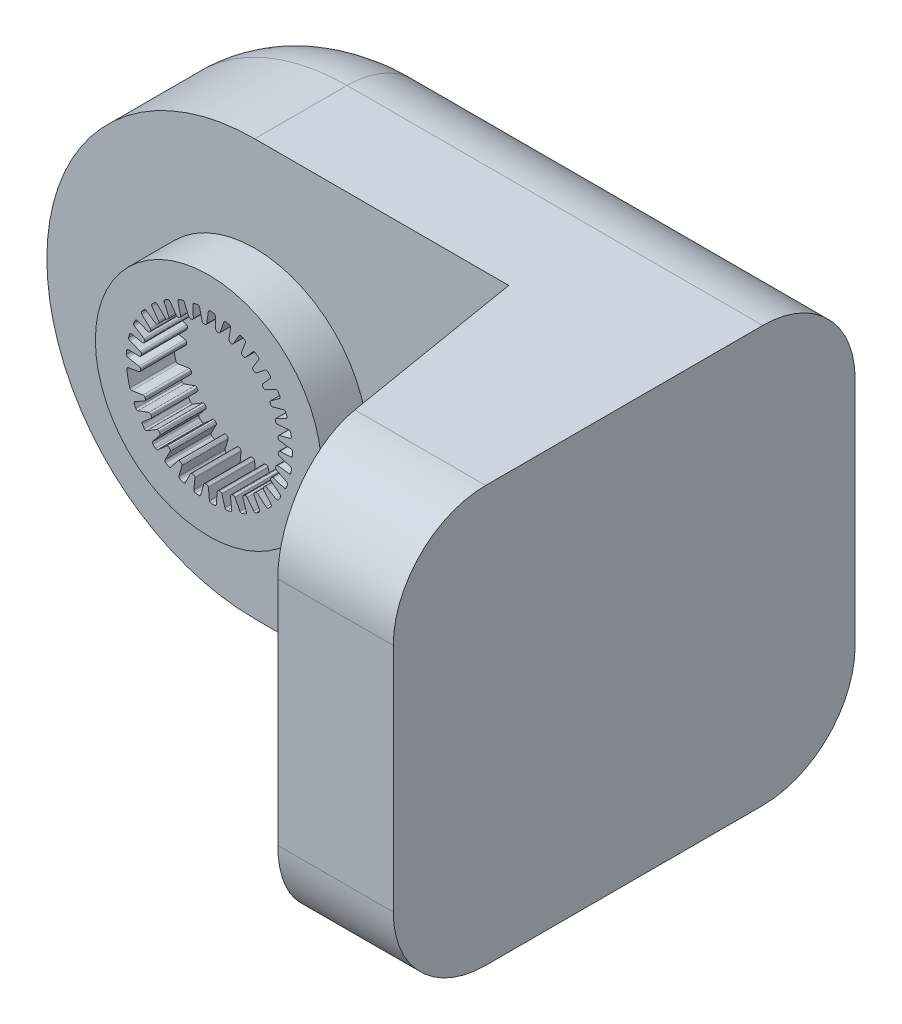
from build123d import *

# Parameters (mm, degrees)
SKETCH1_R           = 24.5
BOSS_EXTRUDE1_DEPTH = 10
BOSS_EXTRUDE3_DEPTH = 40
SKETCH7_W           = 35
SKETCH7_H           = 90
BOSS_EXTRUDE4_DEPTH = 60
CUT_EXTRUDE1_DEPTH  = 91
FILLET1_R           = 20
FILLET2_R           = 20
SCALE1_SCALE        = 0.3


with BuildPart() as part:
    # Sketch1 → Boss-Extrude1 (new body)
    with BuildSketch(Plane.XY):
        with Locations((-0.371975008, 0)):
            Circle(SKETCH1_R)
        with BuildLine():
            Line((-16.969142825, -5.497864624), (-14.564977721, -5.124585631))
            ThreePointArc((-14.564977721, -5.124585631), (-14.29707046, -5.177296982), (-14.125400218, -5.389622476))
            Line((-14.125400218, -5.389622476), (-14.049847687, -5.60904296))
            ThreePointArc((-14.049847687, -5.60904296), (-14.054138659, -5.881349365), (-14.231761388, -6.087793926))
            Line((-14.231761388, -6.087793926), (-16.278130424, -7.240339372))
            ThreePointArc((-16.278130424, -7.240339372), (-16.462911631, -7.467282264), (-16.443705401, -7.759306734))
            ThreePointArc((-16.443705401, -7.759306734), (-16.284490349, -8.088614134), (-16.11861668, -8.414618309))
            ThreePointArc((-16.11861668, -8.414618309), (-15.909353928, -8.602256969), (-15.62830969, -8.605904202))
            Line((-15.62830969, -8.605904202), (-13.33954086, -7.780747067))
            ThreePointArc((-13.33954086, -7.780747067), (-13.06649801, -7.781370848), (-12.857468219, -7.957039097))
            Line((-12.857468219, -7.957039097), (-12.741436398, -8.158012106))
            ThreePointArc((-12.741436398, -8.158012106), (-12.693690022, -8.426134232), (-12.828657842, -8.662677839))
            Line((-12.828657842, -8.662677839), (-14.617513276, -10.1845134))
            ThreePointArc((-14.617513276, -10.1845134), (-14.755596786, -10.442544627), (-14.681022533, -10.725539064))
            ThreePointArc((-14.681022533, -10.725539064), (-14.461897897, -11.018416496), (-14.236867265, -11.306780868))
            ThreePointArc((-14.236867265, -11.306780868), (-13.995646114, -11.451042861), (-13.719069526, -11.400997316))
            Line((-13.719069526, -11.400997316), (-11.62979923, -10.15428296))
            ThreePointArc((-11.62979923, -10.15428296), (-11.361653923, -10.102796248), (-11.122945516, -10.235352213))
            Line((-11.122945516, -10.235352213), (-10.970698069, -10.410492867))
            ThreePointArc((-10.970698069, -10.410492867), (-10.872668815, -10.664578395), (-10.960022248, -10.922529105))
            Line((-10.960022248, -10.922529105), (-12.425631454, -12.757733968))
            ThreePointArc((-12.425631454, -12.757733968), (-12.511943302, -13.037372011), (-12.384741304, -13.300937604))
            ThreePointArc((-12.384741304, -13.300937604), (-12.113758956, -13.546623101), (-11.837840254, -13.786751538))
            ThreePointArc((-11.837840254, -13.786751538), (-11.57352453, -13.882335867), (-11.311578572, -13.780436499))
            Line((-11.311578572, -13.780436499), (-9.49857837, -12.157976231))
            ThreePointArc((-9.49857837, -12.157976231), (-9.245183775, -12.056270938), (-8.985568244, -12.140843765))
            Line((-8.985568244, -12.140843765), (-8.802699599, -12.28371641))
            ThreePointArc((-8.802699599, -12.28371641), (-8.657989614, -12.514428808), (-8.694518802, -12.784308057))
            Line((-8.694518802, -12.784308057), (-9.783027044, -14.865446458))
            ThreePointArc((-9.783027044, -14.865446458), (-9.814395646, -15.15641584), (-9.63924002, -15.390867705))
            ThreePointArc((-9.63924002, -15.390867705), (-9.326357378, -15.580333398), (-9.009689414, -15.763402229))
            ThreePointArc((-9.009689414, -15.763402229), (-8.731991565, -15.806796587), (-8.494301608, -15.656787752))
            Line((-8.494301608, -15.656787752), (-7.02419134, -13.718199902))
            ThreePointArc((-7.02419134, -13.718199902), (-6.794858602, -13.570013254), (-6.523875683, -13.603495261))
            Line((-6.523875683, -13.603495261), (-6.317105464, -13.70884995))
            ThreePointArc((-6.317105464, -13.70884995), (-6.131032208, -13.907711545), (-6.115394864, -14.179602449))
            Line((-6.115394864, -14.179602449), (-6.786804216, -16.430201641))
            ThreePointArc((-6.786804216, -16.430201641), (-6.762076913, -16.721810507), (-6.545403865, -16.918533562))
            ThreePointArc((-6.545403865, -16.918533562), (-6.202118, -17.044817414), (-5.856336939, -17.164099659))
            ThreePointArc((-5.856336939, -17.164099659), (-5.575461147, -17.153709492), (-5.370761259, -16.96110336))
            Line((-5.370761259, -16.96110336), (-4.297561057, -14.777622566))
            ThreePointArc((-4.297561057, -14.777622566), (-4.100717154, -14.588399775), (-3.828324286, -14.569560645))
            Line((-3.828324286, -14.569560645), (-3.605250396, -14.633526053))
            ThreePointArc((-3.605250396, -14.633526053), (-3.384651249, -14.79322955), (-3.317421976, -15.057141307))
            Line((-3.317421976, -15.057141307), (-3.547061077, -17.394501596))
            ThreePointArc((-3.547061077, -17.394501596), (-3.467146489, -17.676034594), (-3.216917807, -17.827800126))
            ThreePointArc((-3.216917807, -17.827800126), (-2.855842975, -17.886261756), (-2.49365476, -17.937374314))
            ThreePointArc((-2.49365476, -17.937374314), (-2.219921985, -17.873581416), (-2.055733994, -17.645455421))
            Line((-2.055733994, -17.645455421), (-1.418879279, -15.297315067))
            ThreePointArc((-1.418879279, -15.297315067), (-1.261757363, -15.074009244), (-0.997963795, -15.003541232))
            Line((-0.997963795, -15.003541232), (-0.766783225, -15.023766911))
            ThreePointArc((-0.766783225, -15.023766911), (-0.519764242, -15.138443903), (-0.403413423, -15.384678908))
            Line((-0.403413423, -15.384678908), (-0.182844038, -17.722912511))
            ThreePointArc((-0.182844038, -17.722912511), (-0.050678678, -17.984024533), (0.223910828, -18.085255821))
            ThreePointArc((0.223910828, -18.085255821), (0.589506703, -18.073747021), (0.954793236, -18.054811727))
            ThreePointArc((0.954793236, -18.054811727), (1.21132451, -17.939960209), (1.328967414, -17.684696986))
            Line((1.328967414, -17.684696986), (1.506075012, -15.258180974))
            ThreePointArc((1.506075012, -15.258180974), (1.617701396, -15.008997633), (1.863202402, -14.889490132))
            Line((1.863202402, -14.889490132), (2.093994776, -14.865232876))
            ThreePointArc((2.093994776, -14.865232876), (2.358356726, -14.930669484), (2.519553706, -15.150179676))
            Line((2.519553706, -15.150179676), (3.182226615, -17.403366719))
            ThreePointArc((3.182226615, -17.403366719), (3.361786248, -17.634463038), (3.650646611, -17.681440275))
            ThreePointArc((3.650646611, -17.681440275), (4.007329478, -17.600383942), (4.362291644, -17.512096587))
            ThreePointArc((4.362291644, -17.512096587), (4.592195013, -17.35040674), (4.658969966, -17.077386096))
            Line((4.658969966, -17.077386096), (4.369822517, -14.661658296))
            ThreePointArc((4.369822517, -14.661658296), (4.431851587, -14.395753836), (4.650038942, -14.231598224))
            Line((4.650038942, -14.231598224), (4.871962507, -14.163749381))
            ThreePointArc((4.871962507, -14.163749381), (5.143953277, -14.177541097), (5.344073133, -14.362260434))
            Line((5.344073133, -14.362260434), (6.424499231, -16.447606133))
            ThreePointArc((6.424499231, -16.447606133), (6.644855104, -16.640194968), (6.937371968, -16.631191945))
            ThreePointArc((6.937371968, -16.631191945), (7.272035289, -16.483566546), (7.603629778, -16.329171304))
            ThreePointArc((7.603629778, -16.329171304), (7.798457298, -16.126584524), (7.811910612, -15.845838777))
            Line((7.811910612, -15.845838777), (7.067133021, -13.529666635))
            ThreePointArc((7.067133021, -13.529666635), (7.077285479, -13.256811885), (7.260141751, -13.054040163))
            Line((7.260141751, -13.054040163), (7.465041785, -12.945092882))
            ThreePointArc((7.465041785, -12.945092882), (7.734666902, -12.906732919), (7.966356105, -13.049873773))
            Line((7.966356105, -13.049873773), (9.42483445, -14.89075078))
            ThreePointArc((9.42483445, -14.89075078), (9.677889447, -15.037755333), (9.963314095, -14.973102872))
            ThreePointArc((9.963314095, -14.973102872), (10.263660453, -14.764332996), (10.559702617, -14.549503217))
            ThreePointArc((10.559702617, -14.549503217), (10.712295226, -14.313463684), (10.671932552, -14.035309014))
            Line((10.671932552, -14.035309014), (9.498892143, -11.903801741))
            ThreePointArc((9.498892143, -11.903801741), (9.456794931, -11.634022921), (9.597600949, -11.400086065))
            Line((9.597600949, -11.400086065), (9.777948272, -11.254043683))
            ThreePointArc((9.777948272, -11.254043683), (10.03530019, -11.164941603), (10.290045172, -11.261244173))
            Line((10.290045172, -11.261244173), (12.072983054, -12.790008296))
            ThreePointArc((12.072983054, -12.790008296), (12.349438509, -12.886026792), (12.617282831, -12.768100588))
            ThreePointArc((12.617282831, -12.768100588), (12.872275811, -12.505857615), (13.121887392, -12.238487357))
            ThreePointArc((13.121887392, -12.238487357), (13.226637979, -11.977668492), (13.133942467, -11.712325868))
            Line((13.133942467, -11.712325868), (11.575743353, -9.84380705))
            ThreePointArc((11.575743353, -9.84380705), (11.48294336, -9.587017353), (11.576525119, -9.330511522))
            Line((11.576525119, -9.330511522), (11.725692753, -9.152740458))
            ThreePointArc((11.725692753, -9.152740458), (11.961314913, -9.016170373), (12.229754908, -9.062095959))
            Line((12.229754908, -9.062095959), (14.271637147, -10.222571794))
            ThreePointArc((14.271637147, -10.222571794), (14.561334529, -10.264075972), (14.801756416, -10.097209299))
            ThreePointArc((14.801756416, -10.097209299), (15.002026138, -9.791129513), (15.196035002, -9.481043465))
            ThreePointArc((15.196035002, -9.481043465), (15.24909444, -9.205029223), (15.107472246, -8.962248828))
            Line((15.107472246, -8.962248828), (13.22137144, -7.42537837))
            ThreePointArc((13.22137144, -7.42537837), (13.08127866, -7.191013697), (13.124197438, -6.921364359))
            Line((13.124197438, -6.921364359), (13.236704125, -6.718396924))
            ThreePointArc((13.236704125, -6.718396924), (13.441938441, -6.539377188), (13.714209453, -6.533238226))
            Line((13.714209453, -6.533238226), (15.940005792, -7.282783352))
            ThreePointArc((15.940005792, -7.282783352), (16.232299988, -7.268248115), (16.436464985, -7.058572594))
            ThreePointArc((16.436464985, -7.058572594), (16.574652412, -6.719903092), (16.705929579, -6.378495562))
            ThreePointArc((16.705929579, -6.378495562), (16.705348165, -6.09742826), (16.520003287, -5.886131214))
            Line((16.520003287, -5.886131214), (14.375306757, -4.737382395))
            ThreePointArc((14.375306757, -4.737382395), (14.193068988, -4.534054623), (14.183747708, -4.261170214))
            Line((14.183747708, -4.261170214), (14.255459317, -4.040464575))
            ThreePointArc((14.255459317, -4.040464575), (14.422764326, -3.825573383), (14.688861583, -3.767595452))
            Line((14.688861583, -3.767595452), (17.016783726, -4.07866736))
            ThreePointArc((17.016783726, -4.07866736), (17.300934201, -4.008626814), (17.461340136, -3.763847105))
            ThreePointArc((17.461340136, -3.763847105), (17.532367484, -3.405032512), (17.596089091, -3.044848735))
            ThreePointArc((17.596089091, -3.044848735), (17.54188819, -2.76905637), (17.319631242, -2.597006915))
            Line((17.319631242, -2.597006915), (14.99514722, -1.878591239))
            ThreePointArc((14.99514722, -1.878591239), (14.777460905, -1.713771776), (14.716242083, -1.447679606))
            Line((14.716242083, -1.447679606), (14.744523527, -1.217345731))
            ThreePointArc((14.744523527, -1.217345731), (14.867751498, -0.974479394), (15.117897089, -0.866792932))
            Line((15.117897089, -0.866792932), (17.462404064, -0.727961087))
            ThreePointArc((17.462404064, -0.727961087), (17.727969528, -0.604988917), (17.838722184, -0.334099605))
            ThreePointArc((17.838722184, -0.334099605), (17.839979507, 0.031675211), (17.833804064, 0.397400053))
            ThreePointArc((17.833804064, 0.397400053), (17.727975323, 0.657783316), (17.476973277, 0.784263113))
            Line((17.476973277, 0.784263113), (15.0581164, 1.045947009))
            ThreePointArc((15.0581164, 1.045947009), (14.812980559, 1.166201766), (14.70211372, 1.415723972))
            Line((14.70211372, 1.415723972), (14.685925779, 1.647222319))
            ThreePointArc((14.685925779, 1.647222319), (14.760548624, 1.909139522), (14.985550789, 2.06257751))
            Line((14.985550789, 2.06257751), (17.260492203, 2.646211643))
            ThreePointArc((17.260492203, 2.646211643), (17.497714285, 2.817596748), (17.554743986, 3.104641663))
            ThreePointArc((17.554743986, 3.104641663), (17.486185083, 3.463936074), (17.410339511, 3.821763191))
            ThreePointArc((17.410339511, 3.821763191), (17.256771672, 4.057169404), (16.986247758, 4.133431962))
            Line((16.986247758, 4.133431962), (14.561900453, 3.928768337))
            ThreePointArc((14.561900453, 3.928768337), (14.298322759, 4.000039553), (14.141881775, 4.223822943))
            Line((14.141881775, 4.223822943), (14.081819284, 4.447979208))
            ThreePointArc((14.081819284, 4.447979208), (14.105094939, 4.719322965), (14.296685833, 4.912874302))
            Line((14.296685833, 4.912874302), (16.418467522, 5.919864718))
            ThreePointArc((16.418467522, 5.919864718), (16.618629347, 6.133365102), (16.6198405, 6.426017974))
            ThreePointArc((16.6198405, 6.426017974), (16.483984611, 6.765629479), (16.341255904, 7.102410286))
            ThreePointArc((16.341255904, 7.102410286), (16.145591916, 7.304189299), (15.865486706, 7.327432303))
            Line((15.865486706, 7.327432303), (13.52473315, 6.663941652))
            ThreePointArc((13.52473315, 6.663941652), (13.252398931, 6.68361042), (13.056132325, 6.873431931))
            Line((13.056132325, 6.873431931), (12.95440232, 7.082009351))
            ThreePointArc((12.95440232, 7.082009351), (12.925475505, 7.352808963), (13.076614998, 7.579361483))
            Line((13.076614998, 7.579361483), (14.967270753, 8.972705682))
            ThreePointArc((14.967270753, 8.972705682), (15.123017247, 9.220476139), (15.068365347, 9.507983253))
            ThreePointArc((15.068365347, 9.507983253), (14.870204584, 9.815432612), (14.665837397, 10.118791886))
            ThreePointArc((14.665837397, 10.118791886), (14.435267057, 10.279529201), (14.155873194, 10.248898572))
            Line((14.155873194, 10.248898572), (11.984725859, 9.150961278))
            ThreePointArc((11.984725859, 9.150961278), (11.713642209, 9.118304857), (11.484761921, 9.267189378))
            Line((11.484761921, 9.267189378), (11.345102535, 9.452523643))
            ThreePointArc((11.345102535, 9.452523643), (11.265036185, 9.712828408), (11.370170562, 9.964057294))
            Line((11.370170562, 9.964057294), (12.960227038, 11.692555961))
            ThreePointArc((12.960227038, 11.692555961), (13.065835198, 11.965492009), (12.957328464, 12.237288733))
            ThreePointArc((12.957328464, 12.237288733), (12.704144369, 12.501278525), (12.445648304, 12.760069138))
            ThreePointArc((12.445648304, 12.760069138), (12.188644066, 12.87385836), (11.920228055, 12.79047964))
            Line((11.920228055, 12.79047964), (9.998467123, 11.298440105))
            ThreePointArc((9.998467123, 11.298440105), (9.738595182, 11.214658475), (9.485511563, 11.317135151))
            Line((9.485511563, 11.317135151), (9.313054669, 11.472416036))
            ThreePointArc((9.313054669, 11.472416036), (9.184790873, 11.712660889), (9.240056903, 11.979334578))
            Line((9.240056903, 11.979334578), (10.47108647, 13.979472934))
            ThreePointArc((10.47108647, 13.979472934), (10.522675657, 14.267545366), (10.364301238, 14.513644357))
            ThreePointArc((10.364301238, 14.513644357), (10.065397221, 14.724474111), (9.76227088, 14.929186636))
            ThreePointArc((9.76227088, 14.929186636), (9.488276526, 14.99184651), (9.240701483, 14.858783502))
            Line((9.240701483, 14.858783502), (7.638943277, 13.027467663))
            ThreePointArc((7.638943277, 13.027467663), (7.399832204, 12.895639434), (7.131844973, 12.947942693))
            Line((7.131844973, 12.947942693), (6.932927607, 13.067464305))
            ThreePointArc((6.932927607, 13.067464305), (6.7611795, 13.278821297), (6.764546399, 13.551140695))
            Line((6.764546399, 13.551140695), (7.591314094, 15.749422391))
            ThreePointArc((7.591314094, 15.749422391), (7.586988632, 16.042045802), (7.384566095, 16.253403998))
            ThreePointArc((7.384566095, 16.253403998), (7.050925573, 16.40332664), (6.714307526, 16.546438787))
            ThreePointArc((6.714307526, 16.546438787), (6.433391152, 16.555666835), (6.215754379, 16.377809024))
            Line((6.215754379, 16.377809024), (4.992856518, 14.274509741))
            ThreePointArc((4.992856518, 14.274509741), (4.783292601, 14.099479023), (4.510249118, 14.09968695))
            Line((4.510249118, 14.09968695), (4.292180626, 14.17905739))
            ThreePointArc((4.292180626, 14.17905739), (4.0832592, 14.353760076), (4.034603248, 14.621718634))
            Line((4.034603248, 14.621718634), (4.426728971, 16.937366417))
            ThreePointArc((4.426728971, 16.937366417), (4.3666478, 17.223788175), (4.127615291, 17.392639084))
            ThreePointArc((4.127615291, 17.392639084), (3.771498096, 17.476145612), (3.413757585, 17.552398635))
            ThreePointArc((3.413757585, 17.552398635), (3.136241642, 17.507855766), (2.956540339, 17.29173865))
            Line((2.956540339, 17.29173865), (2.15743898, 14.993742987))
            ThreePointArc((2.15743898, 14.993742987), (1.985122778, 14.781941396), (1.717056198, 14.73004635))
            Line((1.717056198, 14.73004635), (1.487849644, 14.766349102))
            ThreePointArc((1.487849644, 14.766349102), (1.249431849, 14.897977919), (1.150540941, 15.151729331))
            Line((1.150540941, 15.151729331), (1.093615783, 17.499653257))
            ThreePointArc((1.093615783, 17.499653257), (0.979986625, 17.769348613), (0.713127543, 17.889487702))
            ThreePointArc((0.713127543, 17.889487702), (0.347619428, 17.903509616), (-0.018098145, 17.910101548))
            ThreePointArc((-0.018098145, 17.910101548), (-0.282016159, 17.81342452), (-0.417178752, 17.566989459))
            Line((-0.417178752, 17.566989459), (-0.763120125, 15.15873872))
            ThreePointArc((-0.763120125, 15.15873872), (-0.891856745, 14.91794904), (-1.145096145, 14.815857937))
            Line((-1.145096145, 14.815857937), (-1.37701842, 14.807759033))
            ThreePointArc((-1.37701842, 14.807759033), (-1.636171771, 14.891477199), (-1.781663826, 15.121697207))
            Line((-1.781663826, 15.121697207), (-2.285548115, 17.415621326))
            ThreePointArc((-2.285548115, 17.415621326), (-2.448549885, 17.658680152), (-2.733429633, 17.725692835))
            ThreePointArc((-2.733429633, 17.725692835), (-3.094897842, 17.669714891), (-3.455153952, 17.606403508))
            ThreePointArc((-3.455153952, 17.606403508), (-3.695776202, 17.461144777), (-3.781433452, 17.193447184))
            Line((-3.781433452, 17.193447184), (-3.661503004, 14.763434069))
            ThreePointArc((-3.661503004, 14.763434069), (-3.741929532, 14.502504268), (-3.97103631, 14.353968511))
            Line((-3.97103631, 14.353968511), (-4.197152176, 14.30176555))
            ThreePointArc((-4.197152176, 14.30176555), (-4.467518329, 14.334496787), (-4.654265334, 14.532725812))
            Line((-4.654265334, 14.532725812), (-5.586593206, 16.688358429))
            ThreePointArc((-5.586593206, 16.688358429), (-5.792977985, 16.895849376), (-6.085410312, 16.907273229))
            ThreePointArc((-6.085410312, 16.907273229), (-6.429556237, 16.783352371), (-6.771113046, 16.65246409))
            ThreePointArc((-6.771113046, 16.65246409), (-6.979597716, 16.463961282), (-7.012602092, 16.184837873))
            Line((-7.012602092, 16.184837873), (-6.431206742, 13.822354752))
            ThreePointArc((-6.431206742, 13.822354752), (-6.460367855, 13.550872862), (-6.656923338, 13.36135049))
            Line((-6.656923338, 13.36135049), (-6.868924024, 13.266961704))
            ThreePointArc((-6.868924024, 13.266961704), (-7.140568204, 13.247503281), (-7.361708022, 13.406457273))
            Line((-7.361708022, 13.406457273), (-8.688220498, 15.344588302))
            ThreePointArc((-8.688220498, 15.344588302), (-8.930404547, 15.508886984), (-9.219643842, 15.46430223))
            ThreePointArc((-9.219643842, 15.46430223), (-9.533821622, 15.276992009), (-9.84412841, 15.083336403))
            ThreePointArc((-9.84412841, 15.083336403), (-10.012814597, 14.858516172), (-9.991953333, 14.578223515))
            Line((-9.991953333, 14.578223515), (-8.970456822, 12.370081325))
            ThreePointArc((-8.970456822, 12.370081325), (-8.947280977, 12.098023119), (-9.104062609, 11.874478253))
            Line((-9.104062609, 11.874478253), (-9.294158016, 11.741372016))
            ThreePointArc((-9.294158016, 11.741372016), (-9.557098485, 11.670438947), (-9.804505193, 11.784277039))
            Line((-9.804505193, 11.784277039), (-11.476458734, 13.43368863))
            ThreePointArc((-11.476458734, 13.43368863), (-11.745542845, 13.548757787), (-12.020960828, 13.449802721))
            ThreePointArc((-12.020960828, 13.449802721), (-12.293625803, 13.20598597), (-12.561280149, 12.956679036))
            ThreePointArc((-12.561280149, 12.956679036), (-12.683969373, 12.703802544), (-12.610009029, 12.43264017))
            Line((-12.610009029, 12.43264017), (-11.185946893, 10.459978494))
            ThreePointArc((-11.185946893, 10.459978494), (-11.1112857, 10.197340923), (-11.222532441, 9.947987861))
            Line((-11.222532441, 9.947987861), (-11.383737393, 9.781055247))
            ThreePointArc((-11.383737393, 9.781055247), (-11.628312237, 9.661254011), (-11.892894719, 9.725793152))
            Line((-11.892894719, 9.725793152), (-13.848852332, 11.02587663))
            ThreePointArc((-13.848852332, 11.02587663), (-14.134948842, 11.087487974), (-14.386425104, 10.937798763))
            ThreePointArc((-14.386425104, 10.937798763), (-14.607558025, 10.646434682), (-14.822724802, 10.350637362))
            ThreePointArc((-14.822724802, 10.350637362), (-14.89490877, 10.078996716), (-14.770567065, 9.826928657))
            Line((-14.770567065, 9.826928657), (-12.996267369, 8.162234197))
            ThreePointArc((-12.996267369, 8.162234197), (-12.872864302, 7.918668046), (-12.934488319, 7.652669423))
            Line((-12.934488319, 7.652669423), (-13.060879237, 7.458044476))
            ThreePointArc((-13.060879237, 7.458044476), (-13.278101399, 7.293777246), (-13.550137405, 7.306645904))
            Line((-13.550137405, 7.306645904), (-15.71822619, 8.209628879))
            ThreePointArc((-15.71822619, 8.209628879), (-16.010822299, 8.215518462), (-16.229116186, 8.02059553))
            ThreePointArc((-16.229116186, 8.02059553), (-16.390591385, 7.692390478), (-16.545364153, 7.360972031))
            ThreePointArc((-16.545364153, 7.360972031), (-16.56439042, 7.080548838), (-16.394236369, 6.856837495))
            Line((-16.394236369, 6.856837495), (-14.334896879, 5.561280504))
            ThreePointArc((-14.334896879, 5.561280504), (-14.16728646, 5.345735764), (-14.177023341, 5.072865868))
            Line((-14.177023341, 5.072865868), (-14.263955911, 4.857700206))
            ThreePointArc((-14.263955911, 4.857700206), (-14.445843425, 4.655003085), (-14.715336818, 4.615728392))
            Line((-14.715336818, 4.615728392), (-17.015888981, 5.088430184))
            ThreePointArc((-17.015888981, 5.088430184), (-17.304233061, 5.038381589), (-17.481323225, 4.805387503))
            ThreePointArc((-17.481323225, 4.805387503), (-17.577207194, 4.452401581), (-17.665898729, 4.097540189))
            ThreePointArc((-17.665898729, 4.097540189), (-17.631068162, 3.818638777), (-17.421354184, 3.631504565))
            Line((-17.421354184, 3.631504565), (-15.152646632, 2.752691104))
            ThreePointArc((-15.152646632, 2.752691104), (-14.946987814, 2.573088104), (-14.90447977, 2.303373712))
            Line((-14.90447977, 2.303373712), (-14.9487596, 2.075573732))
            ThreePointArc((-14.9487596, 2.075573732), (-15.088628894, 1.841894954), (-15.34567697, 1.751920085))
            Line((-15.34567697, 1.751920085), (-17.694157264, 1.776970967))
            ThreePointArc((-17.694157264, 1.776970967), (-17.967653929, 1.672823261), (-18.09703308, 1.410319536))
            ThreePointArc((-18.09703308, 1.410319536), (-18.123802502, 1.045523436), (-18.143153778, 0.680258704))
            ThreePointArc((-18.143153778, 0.680258704), (-18.055746248, 0.413127482), (-17.814178415, 0.269446766))
            Line((-17.814178415, 0.269446766), (-15.419467897, -0.160330607))
            ThreePointArc((-15.419467897, -0.160330607), (-15.183317743, -0.297392242), (-15.090126759, -0.554040304))
            Line((-15.090126759, -0.554040304), (-15.090126759, -0.786103946))
            ThreePointArc((-15.090126759, -0.786103946), (-15.182838247, -1.042177706), (-15.417995612, -1.179546569))
            Line((-15.417995612, -1.179546569), (-17.728107642, -1.603067108))
            ThreePointArc((-17.728107642, -1.603067108), (-17.976707083, -1.757486951), (-18.053621104, -2.039854449))
            ThreePointArc((-18.053621104, -2.039854449), (-17.805412438, -3.642620368), (-17.413942426, -5.216538207))
            ThreePointArc((-17.413942426, -5.216538207), (-17.244327564, -5.440658632), (-16.969142825, -5.497864624))
        make_face(mode=Mode.SUBTRACT)
    extrude(amount=BOSS_EXTRUDE1_DEPTH)

    # Sketch6 → Boss-Extrude3 (add)
    with BuildSketch(Plane.XY):
        with BuildLine():
            Line((-0.371975008, 45), (89.628024992, 45))
            Line((89.628024992, 45), (89.628024992, -45))
            Line((89.628024992, -45), (-0.371975008, -45))
            ThreePointArc((-0.371975008, -45), (-45.371975008, 0), (-0.371975008, 45))
        make_face()
    extrude(amount=-BOSS_EXTRUDE3_DEPTH)

    # Sketch7 → Boss-Extrude4 (add)
    with BuildSketch(Plane.XY):
        with Locations((72.128024992, 0)):
            Rectangle(SKETCH7_W, SKETCH7_H)
    extrude(amount=BOSS_EXTRUDE4_DEPTH)

    # Sketch8 → Cut-Extrude1 (cut, through all)
    with BuildSketch(Plane(origin=(0, 45, 0), x_dir=(1, 0, 0), z_dir=(0, 1, 0))):
        Polygon((54.628024992, 0), (64.628024992, -60), (54.628024992, -60), align=None)
    extrude(amount=-CUT_EXTRUDE1_DEPTH, mode=Mode.SUBTRACT)

    # Fillet1
    fillet1_edges = [part.edges().sort_by_distance(p)[0] for p in [
        (44.628024992, -45, -40),
        (-45.371975008, 0, -40),
        (44.628024992, 45, -40),
    ]]
    fillet(fillet1_edges, radius=FILLET1_R)

    # Fillet2
    fillet2_edges = [part.edges().sort_by_distance(p)[0] for p in [
        (77.128024992, 45, 60),
        (77.128024992, -45, 60),
    ]]
    fillet(fillet2_edges, radius=FILLET2_R)


with BuildPart() as part_1:
    # Scale1: scaled about (39.329570401, 0.001501823, -6.234323772)
    add(part.part.scale(SCALE1_SCALE).moved(Location((27.530699281, 0.001051276, -4.36402664))))


solid = part_1.part
